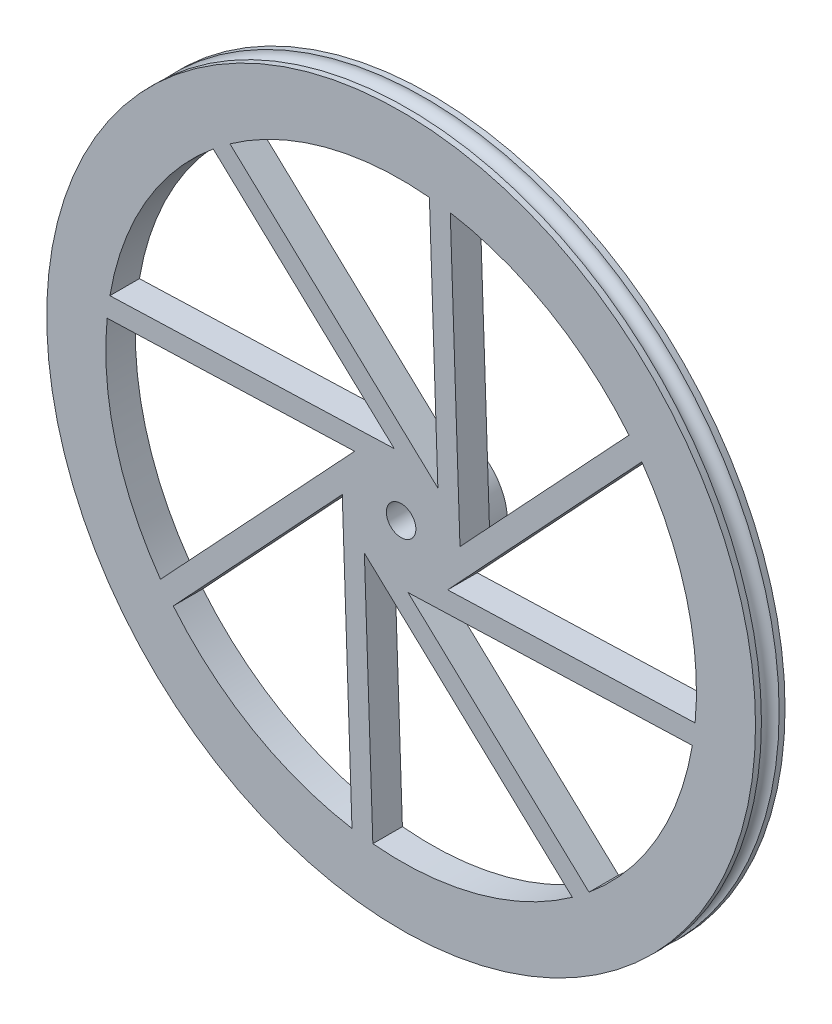
from build123d import *

# Parameters (mm, degrees)
SKETCH1_R           = 60
BOSS_EXTRUDE1_DEPTH = 5
CUT_EXTRUDE2_DEPTH  = 5
SKETCH9_R           = 1.5
SKETCH10_R          = 9
BOSS_EXTRUDE2_DEPTH = 4
CUT_EXTRUDE4_DEPTH  = 4
SKETCH12_R          = 2.5
CUT_EXTRUDE5_DEPTH  = 6


with BuildPart() as part:
    # Sketch1 → Boss-Extrude1 (new body)
    with BuildSketch(Plane.XY):
        Circle(SKETCH1_R)
    extrude(amount=-BOSS_EXTRUDE1_DEPTH)

    # Sketch7 → Cut-Extrude2 (cut)
    with BuildSketch(Plane.XY):
        with BuildLine():
            ThreePointArc((-4.786620503, -49.770355275), (12.911635843, -48.304137088), (28.981073455, -40.744292624))
            Line((28.981073455, -40.744292624), (-6.221076455, -7.872795103))
            Line((-6.221076455, -7.872795103), (-4.786620503, -49.770355275))
        make_face()
        with BuildLine():
            Line((49.303279175, -8.317852043), (1.167941456, -9.965872152))
            Line((1.167941456, -9.965872152), (31.8083039, -38.577607534))
            ThreePointArc((31.8083039, -38.577607534), (43.286088156, -25.026277633), (49.303279175, -8.317852043))
        make_face()
        with BuildLine():
            Line((40.744292624, 28.981073455), (7.872795103, -6.221076455))
            Line((7.872795103, -6.221076455), (49.770355275, -4.786620503))
            ThreePointArc((49.770355275, -4.786620503), (49.94255582, -2.396063049), (50, 0))
            ThreePointArc((50, 0), (47.629899387, 15.211597037), (40.744292624, 28.981073455))
        make_face()
        with BuildLine():
            Line((9.965872152, 1.167941456), (38.577607534, 31.8083039))
            ThreePointArc((38.577607534, 31.8083039), (25.026277633, 43.286088156), (8.317852043, 49.303279175))
            Line((8.317852043, 49.303279175), (9.965872152, 1.167941456))
        make_face()
        with BuildLine():
            Line((6.221076455, 7.872795103), (4.786620503, 49.770355275))
            ThreePointArc((4.786620503, 49.770355275), (-12.911635843, 48.304137088), (-28.981073455, 40.744292624))
            Line((-28.981073455, 40.744292624), (6.221076455, 7.872795103))
        make_face()
        with BuildLine():
            Line((-1.167941456, 9.965872152), (-31.8083039, 38.577607534))
            ThreePointArc((-31.8083039, 38.577607534), (-43.286088156, 25.026277633), (-49.303279175, 8.317852043))
            Line((-49.303279175, 8.317852043), (-1.167941456, 9.965872152))
        make_face()
        with BuildLine():
            ThreePointArc((-49.770355275, 4.786620503), (-48.304137088, -12.911635843), (-40.744292624, -28.981073455))
            Line((-40.744292624, -28.981073455), (-7.872795103, 6.221076455))
            Line((-7.872795103, 6.221076455), (-49.770355275, 4.786620503))
        make_face()
        with BuildLine():
            ThreePointArc((-38.577607534, -31.8083039), (-25.026277633, -43.286088156), (-8.317852043, -49.303279175))
            Line((-8.317852043, -49.303279175), (-9.965872152, -1.167941456))
            Line((-9.965872152, -1.167941456), (-38.577607534, -31.8083039))
        make_face()
    extrude(amount=-CUT_EXTRUDE2_DEPTH, mode=Mode.SUBTRACT)

    # Sketch9 → Cut-Revolve3 (revolve, cut)
    with BuildSketch(Plane(origin=(0, 0, 0), x_dir=(1, 0, 0), z_dir=(0, 1, 0))):
        with Locations((-60, 2.5)):
            Circle(SKETCH9_R)
    revolve(axis=Axis((0, 0, -92.148103423), (0, 0, 1)), mode=Mode.SUBTRACT)

    # Sketch10 → Boss-Extrude2 (add)
    with BuildSketch(Plane(origin=(0, 0, -5), x_dir=(-1, 0, 0), z_dir=(0, 0, -1))):
        Circle(SKETCH10_R)
    extrude(amount=BOSS_EXTRUDE2_DEPTH)

    # Sketch11 → Cut-Extrude4 (cut)
    with BuildSketch(Plane(origin=(0, 0, -9), x_dir=(-1, 0, 0), z_dir=(0, 0, -1))):
        Polygon((7, 0), (3.5, 6.062177826), (-3.5, 6.062177826), (-7, 0), (-3.5, -6.062177826), (3.5, -6.062177826), align=None)
    extrude(amount=-CUT_EXTRUDE4_DEPTH, mode=Mode.SUBTRACT)

    # Sketch12 → Cut-Extrude5 (cut, through all)
    with BuildSketch(Plane(origin=(0, 0, -5), x_dir=(-1, 0, 0), z_dir=(0, 0, -1))):
        Circle(SKETCH12_R)
    extrude(amount=-CUT_EXTRUDE5_DEPTH, mode=Mode.SUBTRACT)


solid = part.part
